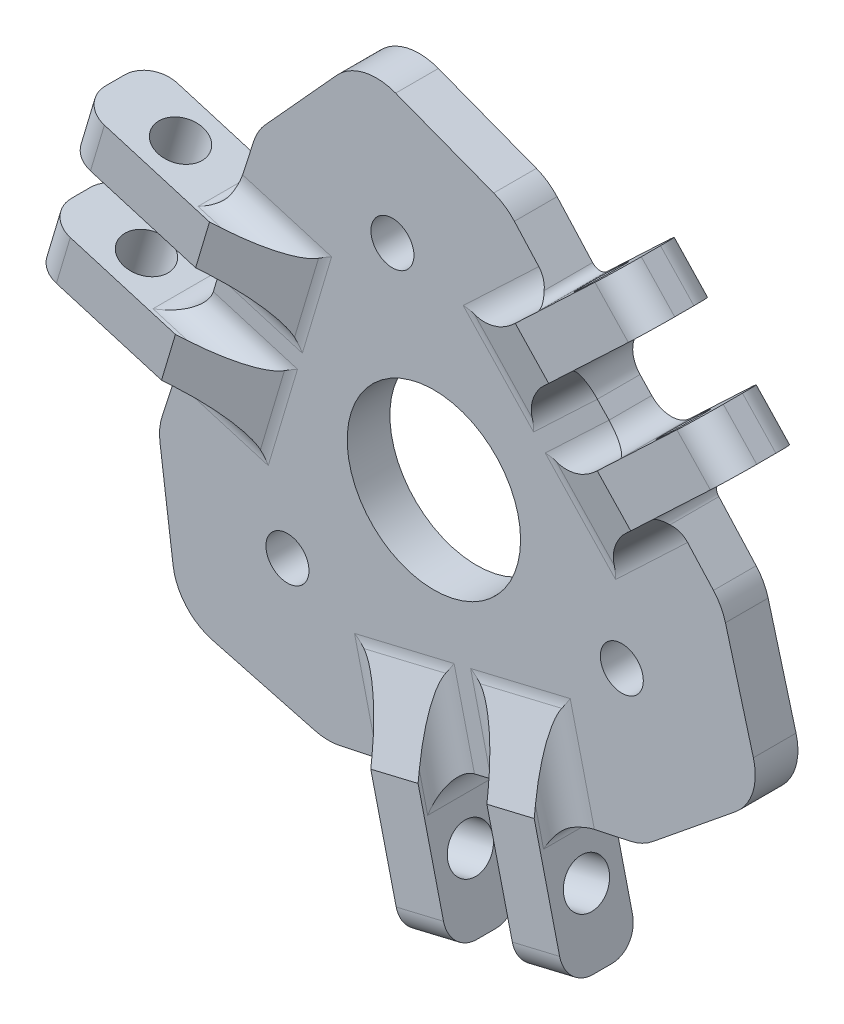
from build123d import *

# Parameters (mm, degrees)
SKETCH1_R                = 1.6
SKETCH1_R_2              = 6.45
BOSS_EXTRUDE1_DEPTH      = 3.175
SKETCH4_R                = 1.675
BOSS_EXTRUDE3_DEPTH      = 6.25
SKETCH4_2_R              = 1.675
CUT_EXTRUDE2_DEPTH       = 2.63125
FILLET1_R                = 2
FILLET2_R                = 2
FILLET3_R                = 2
CIRPATTERN2_COUNT        = 3
FILLET1_OF_CIRPATTERN2_R = 2
FILLET2_OF_CIRPATTERN2_R = 2
FILLET3_OF_CIRPATTERN2_R = 2
FILLET5_R                = 0.75


with BuildPart() as part:
    # Sketch1 → Boss-Extrude1 (new body)
    with BuildSketch(Plane.XY):
        with BuildLine():
            Line((15.347308801, 31.210973101), (8.051491314, 33.998880179))
            ThreePointArc((8.051491314, 33.998880179), (5.696175566, 34.15336703), (3.663829908, 32.952971436))
            Line((3.663829908, 32.952971436), (-1.653149933, 27.103867562))
            ThreePointArc((-1.653149933, 27.103867562), (-2.154824203, 26.417727613), (-2.500196213, 25.641078866))
            Line((-2.500196213, 25.641078866), (-9.325438013, 4.478720632))
            ThreePointArc((-9.325438013, 4.478720632), (-9.502063256, 3.613546149), (-9.484560317, 2.730700176))
            Line((-9.484560317, 2.730700176), (-8.507421128, -4.718687488))
            ThreePointArc((-8.507421128, -4.718687488), (-7.54564448, -6.839386894), (-5.565731281, -8.065080174))
            Line((-5.565731281, -8.065080174), (2.031002829, -10.077591551))
            ThreePointArc((2.031002829, -10.077591551), (2.960636861, -10.209852347), (3.895489669, -10.121746843))
            Line((3.895489669, -10.121746843), (25.485057009, -5.483666514))
            ThreePointArc((25.485057009, -5.483666514), (26.373611638, -5.180049941), (27.166902489, -4.677653705))
            Line((27.166902489, -4.677653705), (33.329625608, 0.328323939))
            ThreePointArc((33.329625608, 0.328323939), (34.614533997, 2.205289229), (34.668387555, 4.479291881))
            Line((34.668387555, 4.479291881), (32.591741985, 12.142614371))
            ThreePointArc((32.591741985, 12.142614371), (32.241466178, 13.013831458), (31.697738169, 13.779384986))
            Line((31.697738169, 13.779384986), (16.88625911, 30.157458595))
            ThreePointArc((16.88625911, 30.157458595), (16.17904213, 30.77516119), (15.347308801, 31.210973101))
        make_face()
        with Locations((24.879793107, 5.344918551)):
            Circle(SKETCH1_R, mode=Mode.SUBTRACT)
        with Locations((7.811061307, 24.218992148)):
            Circle(SKETCH1_R, mode=Mode.SUBTRACT)
        Circle(SKETCH1_R, mode=Mode.SUBTRACT)
        with Locations((10.896951472, 9.8546369)):
            Circle(SKETCH1_R_2, mode=Mode.SUBTRACT)
    extrude(amount=BOSS_EXTRUDE1_DEPTH)

    # Sketch4 → Boss-Extrude3 (add, symmetric)
    with BuildSketch(Plane(origin=(0.449621982, -0.475334512, 0), x_dir=(-0.726482741, -0.687184711, 0), z_dir=(0.687184711, -0.726482741, 0))):
        Polygon((-31.72132028, 0), (-31.72132028, -3.175), (-25.539496086, -3.175), (-31.72132028, -5.425), (-41.88132028, -5.425), (-41.88132028, 0), align=None)
        with Locations((-36.80132028, -2.7125)):
            Circle(SKETCH4_R, mode=Mode.SUBTRACT)
    boss_extrude3 = extrude(amount=BOSS_EXTRUDE3_DEPTH, both=True)

    # Sketch4_2 → Cut-Extrude2 (cut, symmetric)
    with BuildSketch(Plane(origin=(0.449621982, -0.475334512, 0), x_dir=(-0.726482741, -0.687184711, 0), z_dir=(0.687184711, -0.726482741, 0))):
        Polygon((-31.72132028, 0), (-31.72132028, -3.175), (-25.539496086, -3.175), (-31.72132028, -5.425), (-41.88132028, -5.425), (-41.88132028, 0), align=None)
        with Locations((-36.80132028, -2.7125)):
            Circle(SKETCH4_2_R, mode=Mode.SUBTRACT)
    cut_extrude2 = extrude(amount=CUT_EXTRUDE2_DEPTH, both=True, mode=Mode.SUBTRACT)

    # Fillet1
    fillet1_edges = [part.edges().sort_by_distance(p)[0] for p in [
        (19.440964609, 21.110601986, 3.175),
        (23.057274153, 17.287486564, 3.175),
        (25.865326768, 14.96244967, 3.175),
        (17.377217607, 24.139682361, 3.175),
        (22.0551547, 13.848979318, 3.175),
        (15.952095481, 20.301054157, 3.175),
    ]]
    fillet(fillet1_edges, radius=FILLET1_R)

    # Fillet2
    fillet2_edges = [part.edges().sort_by_distance(p)[0] for p in [
        (25.302768444, 19.411514101, 1.5875),
        (21.6864589, 23.234629523, 1.5875),
    ]]
    fillet(fillet2_edges, radius=FILLET2_R)

    # Fillet3
    fillet3_edges = [part.edges().sort_by_distance(p)[0] for p in [
        (27.824148706, 31.530905901, 0),
        (33.927207925, 25.078831062, 0),
        (33.927207925, 25.078831062, 5.425),
        (27.824148706, 31.530905901, 5.425),
    ]]
    fillet(fillet3_edges, radius=FILLET3_R)

    # CirPattern2: Boss-Extrude3, Cut-Extrude2 ×3 about axis
    cirpattern2_axis = Axis((10.896951472, 9.8546369, 0), (0, 0, 1))
    for i in range(1, CIRPATTERN2_COUNT):
        add(boss_extrude3.rotate(cirpattern2_axis, i * 360 / CIRPATTERN2_COUNT))
        add(cut_extrude2.rotate(cirpattern2_axis, i * 360 / CIRPATTERN2_COUNT), mode=Mode.SUBTRACT)

    # Fillet1 of CirPattern2
    fillet1_of_cirpattern2_edges = [part.edges().sort_by_distance(p)[0] for p in [
        (-3.123006806, 11.625986784, 3.175),
        (-1.620246501, 16.669360428, 3.175),
        (-1.010731793, 20.263723774, 3.175),
        (-4.71439386, 8.324189266, 3.175),
        (1.858647852, 17.520753147, 3.175),
        (-0.677483256, 9.009311403, 3.175),
        (16.372896612, -3.172678071, 3.175),
        (11.253826762, -4.392936293, 3.175),
        (7.836259441, -5.662262745, 3.175),
        (20.028030667, -2.899960928, 3.175),
        (8.777051863, -1.805821766, 3.175),
        (17.41624219, 0.253545139, 3.175),
    ]]
    fillet(fillet1_of_cirpattern2_edges, radius=FILLET1_OF_CIRPATTERN2_R)

    # Fillet2 of CirPattern2
    fillet2_of_cirpattern2_edges = [part.edges().sort_by_distance(p)[0] for p in [
        (-4.582455452, 17.552001759, 1.5875),
        (-6.085215757, 12.508628115, 1.5875),
        (11.970541423, -7.399605162, 1.5875),
        (17.089611272, -6.17934694, 1.5875),
    ]]
    fillet(fillet2_of_cirpattern2_edges, radius=FILLET2_OF_CIRPATTERN2_R)

    # Fillet3 of CirPattern2
    fillet3_of_cirpattern2_edges = [part.edges().sort_by_distance(p)[0] for p in [
        (-16.33884676, 13.675885219, 0),
        (-13.802715652, 22.187326963, 0),
        (-13.802715652, 22.187326963, 5.425),
        (-16.33884676, 13.675885219, 5.425),
        (21.205552469, -15.642880421, 0),
        (12.566362141, -17.702247326, 0),
        (12.566362141, -17.702247326, 5.425),
        (21.205552469, -15.642880421, 5.425),
    ]]
    fillet(fillet3_of_cirpattern2_edges, radius=FILLET3_OF_CIRPATTERN2_R)

    # Fillet5
    fillet5_edges = [part.edges().sort_by_distance(p)[0] for p in [
        (-7.789671487, 9.240521362, 1.5875),
        (-3.951849266, 21.140080535, 1.5875),
        (20.879758905, -6.473021336, 1.5875),
        (8.655527257, -9.099149384, 1.5875),
        (20.045714571, 26.663830856, 2.5875),
        (28.432123998, 17.390399731, 2.5875),
    ]]
    fillet(fillet5_edges, radius=FILLET5_R)


solid = part.part
